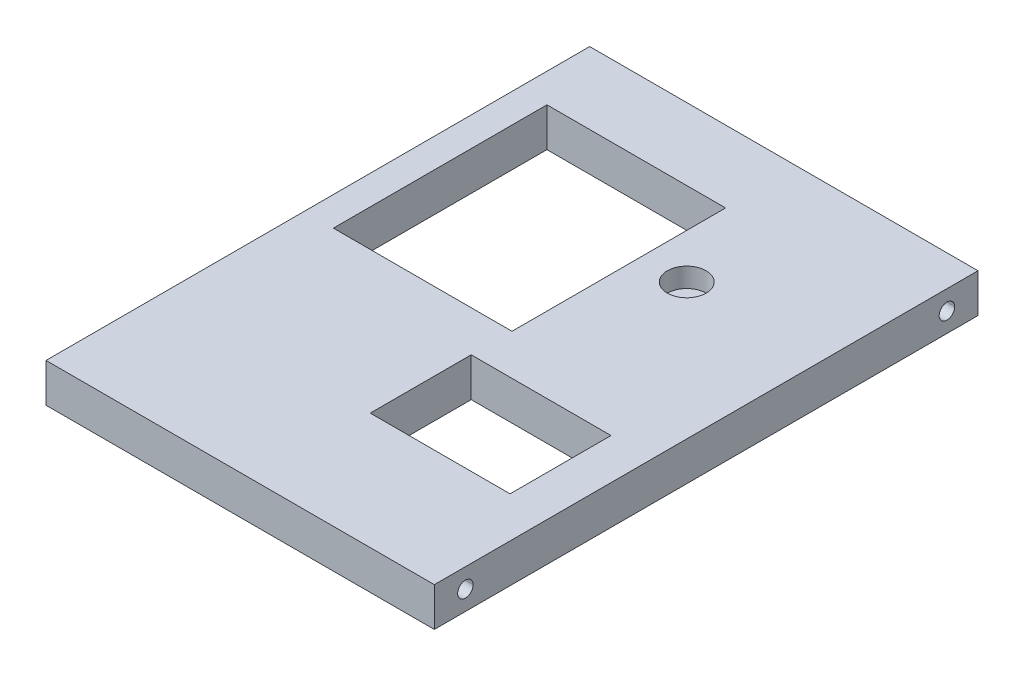
from build123d import *

# Parameters (mm, degrees)
SKETCH2_W           = 100
SKETCH2_H           = 140
BOSS_EXTRUDE1_DEPTH = 10
SKETCH3_R           = 5
MOUNTHOLE_DEPTH     = 5
SKETCH4_R           = 2
CUT_EXTRUDE2_DEPTH  = 173.336879396
SKETCH5_R           = 2
CUT_EXTRUDE3_DEPTH  = 173.336879396
SKETCH21_W          = 46
SKETCH21_H          = 55
SKETCH21_W_2        = 36
SKETCH21_H_2        = 26
CUT_EXTRUDE10_DEPTH = 173.336879396


with BuildPart() as part:
    # Sketch2 → Boss-Extrude1 (new body)
    with BuildSketch(Plane(origin=(0, 0, 0), x_dir=(1, 0, 0), z_dir=(0, 1, 0))):
        with Locations((50, 70)):
            Rectangle(SKETCH2_W, SKETCH2_H)
    extrude(amount=BOSS_EXTRUDE1_DEPTH)

    # Sketch3 → MountHole (cut)
    with BuildSketch(Plane(origin=(0, 10, 0), x_dir=(1, 0, 0), z_dir=(0, 1, 0))):
        with Locations((65, 100)):
            Circle(SKETCH3_R)
    extrude(amount=-MOUNTHOLE_DEPTH, mode=Mode.SUBTRACT)

    # Sketch4 → Cut-Extrude2 (cut, through all)
    with BuildSketch(Plane.ZY):
        with Locations((-8, 5)):
            Circle(SKETCH4_R)
    extrude(amount=-CUT_EXTRUDE2_DEPTH, mode=Mode.SUBTRACT)

    # Sketch5 → Cut-Extrude3 (cut, through all)
    with BuildSketch(Plane.ZY):
        with Locations((-132, 5)):
            Circle(SKETCH5_R)
    extrude(amount=-CUT_EXTRUDE3_DEPTH, mode=Mode.SUBTRACT)

    # Sketch21 → Cut-Extrude10 (cut, through all)
    with BuildSketch(Plane(origin=(0, 10, 0), x_dir=(1, 0, 0), z_dir=(0, 1, 0))):
        with Locations((30.5, 94)):
            Rectangle(SKETCH21_W, SKETCH21_H)
        with Locations((71.5, 43)):
            Rectangle(SKETCH21_W_2, SKETCH21_H_2)
    extrude(amount=-CUT_EXTRUDE10_DEPTH, mode=Mode.SUBTRACT)


solid = part.part
